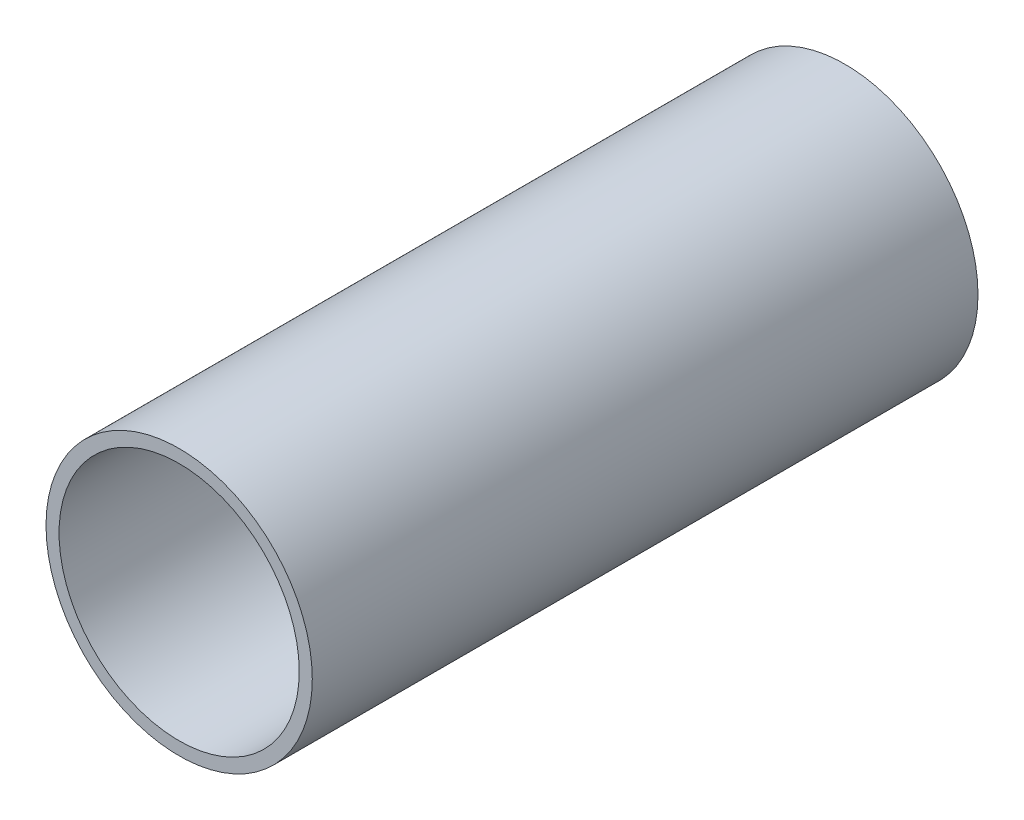
from build123d import *

# Parameters (mm, degrees)
PROFILE_SKETCH_R      = 12.7
PROFILE_SKETCH_R_2    = 11.4554
PROFILE_EXTRUDE_DEPTH = 63.5


with BuildPart() as part:
    # Profile Sketch → Profile Extrude (new body)
    with BuildSketch(Plane.XY):
        Circle(PROFILE_SKETCH_R)
        Circle(PROFILE_SKETCH_R_2, mode=Mode.SUBTRACT)
    extrude(amount=PROFILE_EXTRUDE_DEPTH)


solid = part.part
